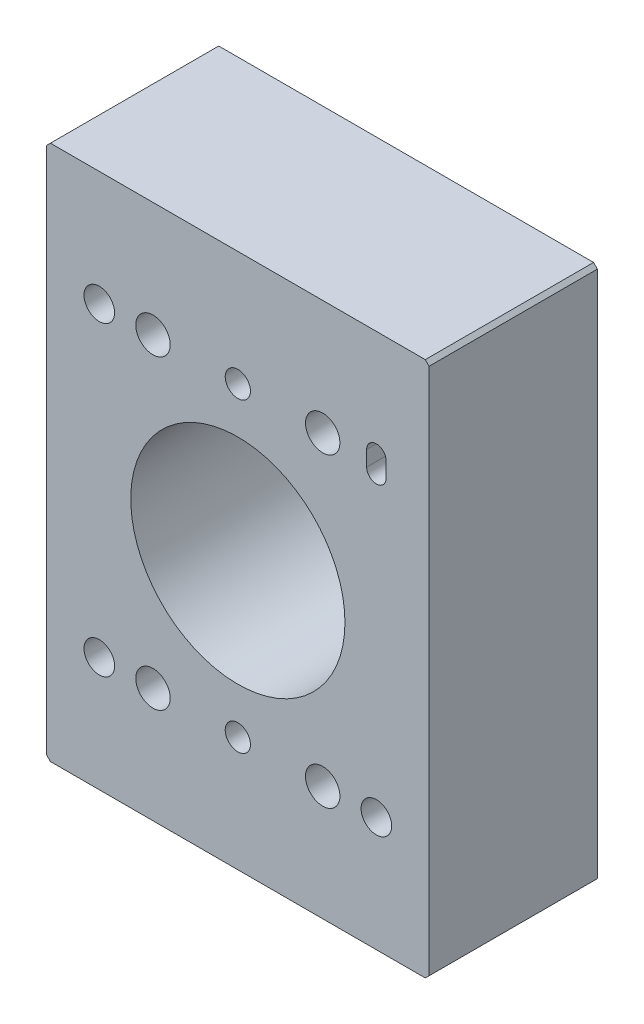
from build123d import *

# Parameters (mm, degrees)
SKETCH1_W           = 50
SKETCH1_H           = 70
SKETCH1_R           = 14
SKETCH1_R_2         = 2
SKETCH1_R_3         = 2.25
BOSS_EXTRUDE1_DEPTH = 22
M4_TAPPED_HOLE1_D   = 3.3
CHAMFER1_SIZE       = 0.5


with BuildPart() as part:
    # Sketch1 → Boss-Extrude1 (new body)
    with BuildSketch(Plane.XY):
        with Locations((5.278422274, -20.544056224)):
            Rectangle(SKETCH1_W, SKETCH1_H)
        with Locations((5.278422274, -20.544056224)):
            Circle(SKETCH1_R, mode=Mode.SUBTRACT)
        with Locations((-12.829698376, -0.544056224)):
            Circle(SKETCH1_R_2, mode=Mode.SUBTRACT)
        with Locations((-5.813457077, -0.544056224)):
            Circle(SKETCH1_R_3, mode=Mode.SUBTRACT)
        with Locations((-5.813457077, -40.544056224)):
            Circle(SKETCH1_R_3, mode=Mode.SUBTRACT)
        with Locations((-12.829698376, -40.544056224)):
            Circle(SKETCH1_R_2, mode=Mode.SUBTRACT)
        with Locations((23.386542923, -40.544056224)):
            Circle(SKETCH1_R_2, mode=Mode.SUBTRACT)
        with Locations((16.370301624, -40.544056224)):
            Circle(SKETCH1_R_3, mode=Mode.SUBTRACT)
        with Locations((16.370301624, -0.544056224)):
            Circle(SKETCH1_R_3, mode=Mode.SUBTRACT)
        with BuildLine():
            Line((22.115366155, 0.455943776), (22.115366155, -1.544056224))
            ThreePointArc((22.115366155, -1.544056224), (23.386542923, -2.815232993), (24.657719692, -1.544056224))
            Line((24.657719692, -1.544056224), (24.657719692, 0.455943776))
            ThreePointArc((24.657719692, 0.455943776), (23.386542923, 1.727120544), (22.115366155, 0.455943776))
        make_face(mode=Mode.SUBTRACT)
    extrude(amount=BOSS_EXTRUDE1_DEPTH)

    # M4 Tapped Hole1 (through all)
    with Locations(Plane.XY.offset(22)):
        with Locations((5.278422274, -0.544056224), (5.278422274, -40.544056224)):
            Hole(M4_TAPPED_HOLE1_D / 2)

    # Chamfer1
    chamfer1_edges = [part.edges().sort_by_distance(p)[0] for p in [
        (-19.721577726, 14.455943776, 11),
        (30.278422274, 14.455943776, 11),
        (30.278422274, -55.544056224, 11),
        (-19.721577726, -55.544056224, 11),
    ]]
    chamfer(chamfer1_edges, length=CHAMFER1_SIZE)


solid = part.part
